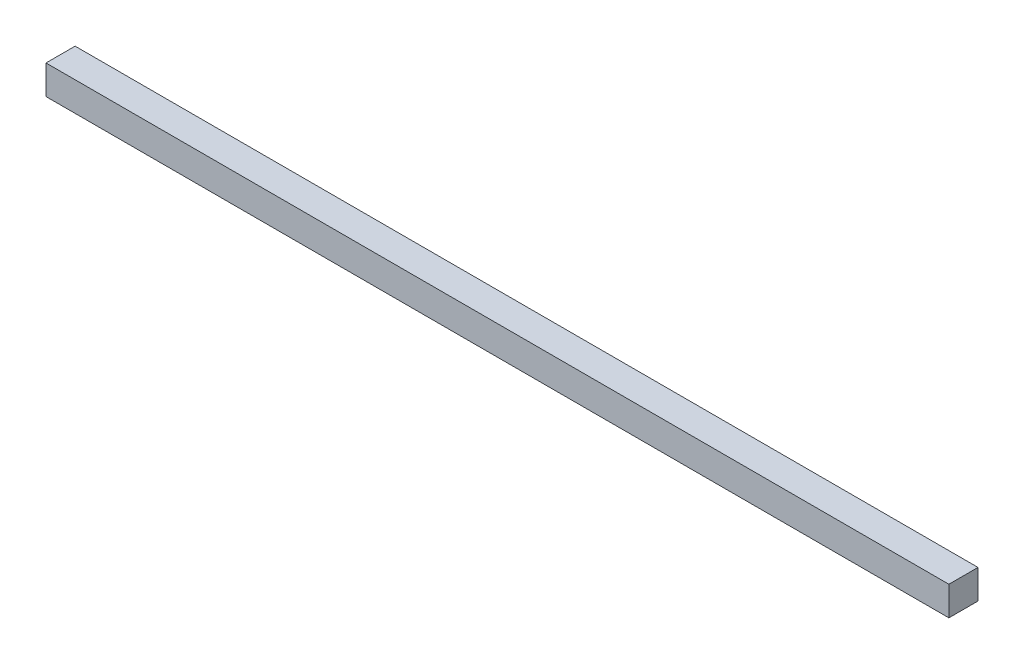
from build123d import *

# Parameters (mm, degrees)
SKETCH1_W           = 310
SKETCH1_H           = 10
BOSS_EXTRUDE1_DEPTH = 10


with BuildPart() as part:
    # Sketch1 → Boss-Extrude1 (new body)
    with BuildSketch(Plane(origin=(0, 0, 0), x_dir=(1, 0, 0), z_dir=(0, 1, 0))):
        Rectangle(SKETCH1_W, SKETCH1_H)
    extrude(amount=BOSS_EXTRUDE1_DEPTH)


solid = part.part
